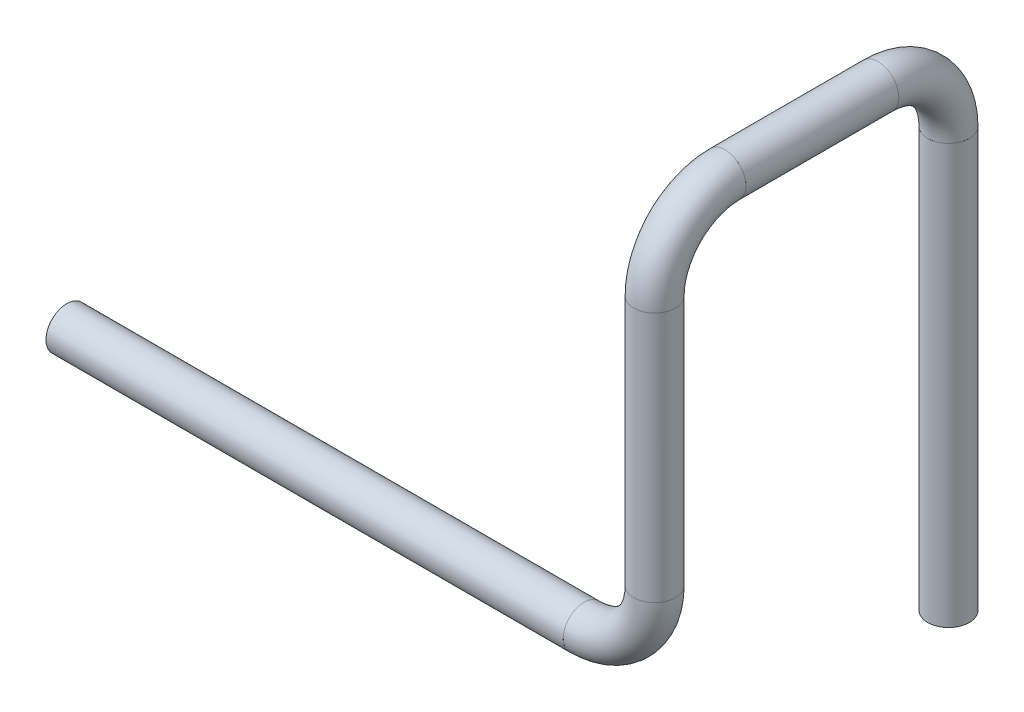
from build123d import *

# Parameters (mm, degrees)
SKETCH1_R                 = 10.65
SKETCH1_R_2               = 8.35
ROHR_21_3_X_2_3_1_DEPTH   = 264
SKETCH1_ON_SEGMENT_2_R    = 10.65
SKETCH1_ON_SEGMENT_2_R_2  = 8.35
ROHR_21_3_X_2_3_1_2_ANGLE = 90
SKETCH1_ON_SEGMENT_3_R    = 10.65
SKETCH1_ON_SEGMENT_3_R_2  = 8.35
ROHR_21_3_X_2_3_1_3_DEPTH = 128
SKETCH1_ON_SEGMENT_4_R    = 10.65
SKETCH1_ON_SEGMENT_4_R_2  = 8.35
ROHR_21_3_X_2_3_1_4_ANGLE = 90
SKETCH1_ON_SEGMENT_5_R    = 10.65
SKETCH1_ON_SEGMENT_5_R_2  = 8.35
ROHR_21_3_X_2_3_1_5_DEPTH = 78
SKETCH1_ON_SEGMENT_6_R    = 10.65
SKETCH1_ON_SEGMENT_6_R_2  = 8.35
ROHR_21_3_X_2_3_1_6_ANGLE = 90
SKETCH1_ON_SEGMENT_7_R    = 10.65
SKETCH1_ON_SEGMENT_7_R_2  = 8.35
ROHR_21_3_X_2_3_1_7_DEPTH = 214


with BuildPart() as part:
    # Sketch1 → Rohr 21.3 X 2.3(1) (new body)
    with BuildSketch(Plane(origin=(0, 0, 0), x_dir=(0, 0, -1), z_dir=(1, 0, 0))):
        Circle(SKETCH1_R)
        Circle(SKETCH1_R_2, mode=Mode.SUBTRACT)
    extrude(amount=ROHR_21_3_X_2_3_1_DEPTH)


with BuildPart() as body_2:
    # Sketch1 on segment 2 (carried to the start of arc 2) → Rohr 21.3 X 2.3_1 2 (revolve)
    with BuildSketch(Plane(origin=(264, 0, 0), x_dir=(0, 0, -1), z_dir=(1, 0, 0))):
        Circle(SKETCH1_ON_SEGMENT_2_R)
        Circle(SKETCH1_ON_SEGMENT_2_R_2, mode=Mode.SUBTRACT)
    revolve(axis=Axis((264, 36, 0), (0, 0, 1)), revolution_arc=ROHR_21_3_X_2_3_1_2_ANGLE)


with BuildPart() as body_3:
    # Sketch1 on segment 3 (carried to segment 3) → Rohr 21.3 X 2.3_1 3 (new body)
    with BuildSketch(Plane(origin=(300, 36, 0), x_dir=(0, 0, -1), z_dir=(0, 1, 0))):
        Circle(SKETCH1_ON_SEGMENT_3_R)
        Circle(SKETCH1_ON_SEGMENT_3_R_2, mode=Mode.SUBTRACT)
    extrude(amount=ROHR_21_3_X_2_3_1_3_DEPTH)


with BuildPart() as body_4:
    # Sketch1 on segment 4 (carried to the start of arc 4) → Rohr 21.3 X 2.3_1 4 (revolve)
    with BuildSketch(Plane(origin=(300, 164, 0), x_dir=(0, 0, -1), z_dir=(0, 1, 0))):
        Circle(SKETCH1_ON_SEGMENT_4_R)
        Circle(SKETCH1_ON_SEGMENT_4_R_2, mode=Mode.SUBTRACT)
    revolve(axis=Axis((300, 164, -36), (-1, 0, 0)), revolution_arc=ROHR_21_3_X_2_3_1_4_ANGLE)


with BuildPart() as body_5:
    # Sketch1 on segment 5 (carried to segment 5) → Rohr 21.3 X 2.3_1 5 (new body)
    with BuildSketch(Plane(origin=(300, 200, -36), x_dir=(-1, 0, 0), z_dir=(0, 0, -1))):
        Circle(SKETCH1_ON_SEGMENT_5_R)
        Circle(SKETCH1_ON_SEGMENT_5_R_2, mode=Mode.SUBTRACT)
    extrude(amount=ROHR_21_3_X_2_3_1_5_DEPTH)


with BuildPart() as body_6:
    # Sketch1 on segment 6 (carried to the start of arc 6) → Rohr 21.3 X 2.3_1 6 (revolve)
    with BuildSketch(Plane(origin=(300, 200, -114), x_dir=(-1, 0, 0), z_dir=(0, 0, -1))):
        Circle(SKETCH1_ON_SEGMENT_6_R)
        Circle(SKETCH1_ON_SEGMENT_6_R_2, mode=Mode.SUBTRACT)
    revolve(axis=Axis((300, 164, -114), (-1, 0, 0)), revolution_arc=ROHR_21_3_X_2_3_1_6_ANGLE)


with BuildPart() as body_7:
    # Sketch1 on segment 7 (carried to segment 7) → Rohr 21.3 X 2.3_1 7 (new body)
    with BuildSketch(Plane(origin=(300, 164, -150), x_dir=(0, 0, -1), z_dir=(0, -1, 0))):
        Circle(SKETCH1_ON_SEGMENT_7_R)
        Circle(SKETCH1_ON_SEGMENT_7_R_2, mode=Mode.SUBTRACT)
    extrude(amount=ROHR_21_3_X_2_3_1_7_DEPTH)


solid = Compound([part.part, body_2.part, body_3.part, body_4.part, body_5.part, body_6.part, body_7.part])
